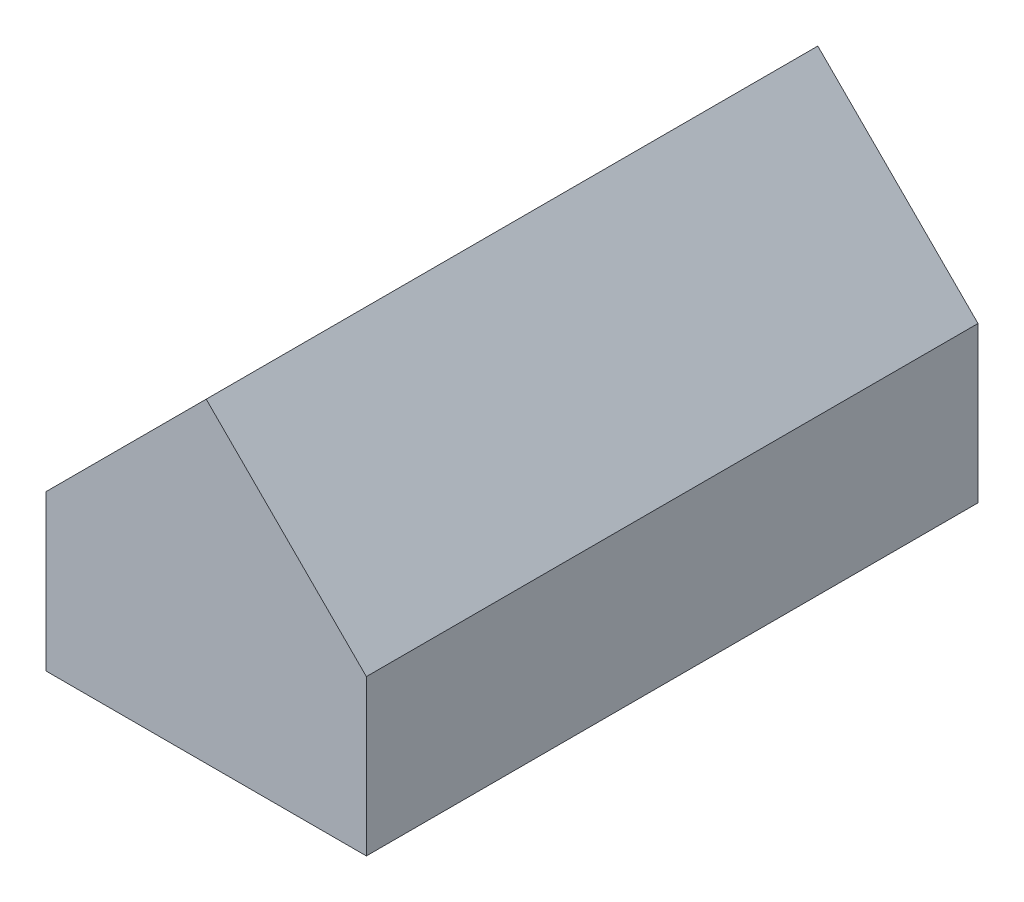
from build123d import *

# Parameters (mm, degrees)
EXTRUDE_1_DEPTH = 6100
EXTRUDE_4_DEPTH = 100
EXTRUDE_5_DEPTH = 100
EXTRUDE_3_DEPTH = 50


with BuildPart() as part:
    # 草图1 → 凸台-拉伸1 (new body)
    with BuildSketch(Plane.XY):
        Polygon((0, 0), (-150, 0), (-150, 1600), (1500.000128285, 3249.999871715), (3150, 1599.999743429), (3150, -0.000256571), (3000, -0.000256571), (3000, 1599.999743429), (1500.000116623, 3099.999860052), (0, 1599.999976675), align=None)
    extrude(amount=EXTRUDE_1_DEPTH)

    # 草图4 → 凸台-拉伸4 (add)
    with BuildSketch(Plane(origin=(0, 0, 0), x_dir=(-1, 0, 0), z_dir=(0, 0, -1))):
        Polygon((-3150, 1599.999743429), (-3150, -0.000256571), (150, 0), (150, 1600), (-1500.000128285, 3249.999871715), align=None)
    extrude(amount=EXTRUDE_4_DEPTH)

    # 草图5 → 凸台-拉伸5 (add)
    with BuildSketch(Plane.XY.offset(6100)):
        Polygon((-150, 1600), (-150, 0), (3150, -0.000256571), (3150, 1599.999743429), (1500.000128285, 3249.999871715), align=None)
    extrude(amount=EXTRUDE_5_DEPTH)

    # 草图3 → 凸台-拉伸3 (add)
    with BuildSketch(Plane(origin=(0, 0, 0), x_dir=(-1, 0, 0), z_dir=(0, 0, -1))):
        Polygon((-3150, 0), (-3150, 1599.999743429), (-1500.000128285, 3249.999871715), (150, 1600), (150, 0), align=None)
    extrude(amount=EXTRUDE_3_DEPTH)


solid = part.part
